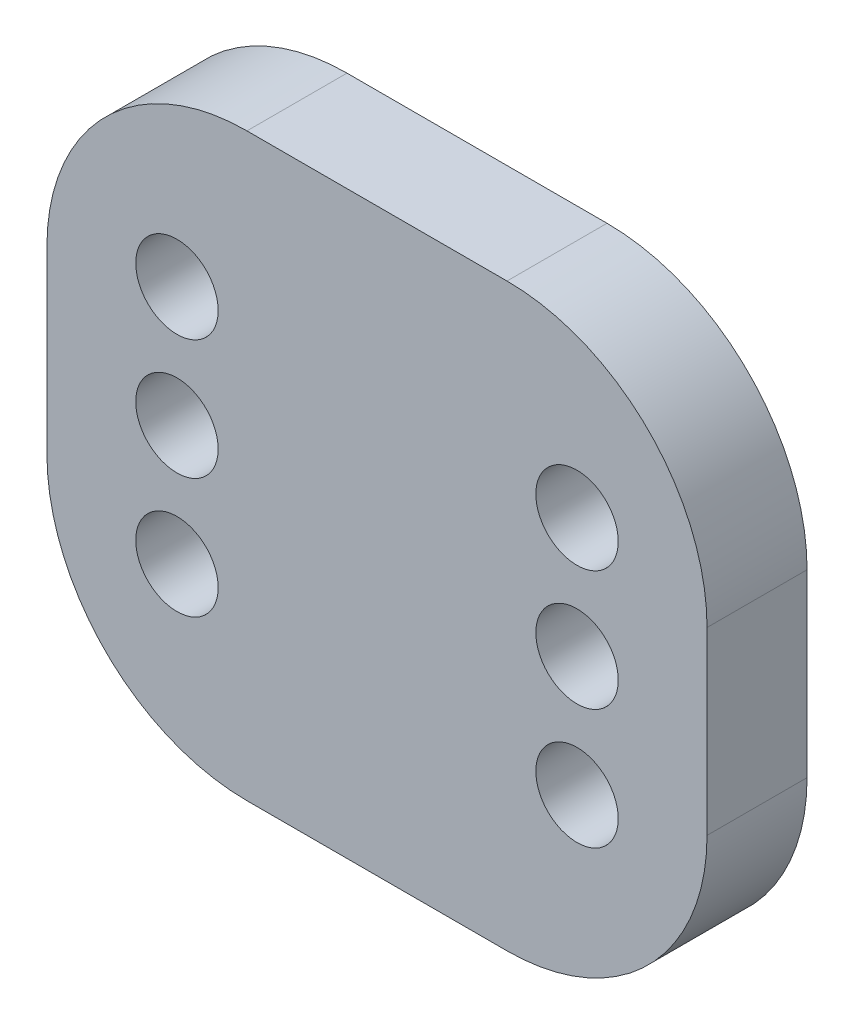
from build123d import *

# Parameters (mm, degrees)
SKETCH2_W           = 41.91
SKETCH2_H           = 36.83
SKETCH2_R           = 2.6162
BOSS_EXTRUDE1_DEPTH = 6.35
FILLET1_R           = 12.7


with BuildPart() as part:
    # Sketch2 → Boss-Extrude1 (new body)
    with BuildSketch(Plane.XY):
        Rectangle(SKETCH2_W, SKETCH2_H)
        with Locations((-12.7, 0)):
            Circle(SKETCH2_R, mode=Mode.SUBTRACT)
        with Locations((12.7, 0)):
            Circle(SKETCH2_R, mode=Mode.SUBTRACT)
        with Locations((-12.7, 7.62)):
            Circle(SKETCH2_R, mode=Mode.SUBTRACT)
        with Locations((12.7, 7.62)):
            Circle(SKETCH2_R, mode=Mode.SUBTRACT)
        with Locations((-12.7, -7.62)):
            Circle(SKETCH2_R, mode=Mode.SUBTRACT)
        with Locations((12.7, -7.62)):
            Circle(SKETCH2_R, mode=Mode.SUBTRACT)
    extrude(amount=BOSS_EXTRUDE1_DEPTH)

    # Fillet1
    fillet1_edges = [part.edges().sort_by_distance(p)[0] for p in [
        (20.955, -18.415, 3.175),
        (-20.955, -18.415, 3.175),
        (-20.955, 18.415, 3.175),
        (20.955, 18.415, 3.175),
    ]]
    fillet(fillet1_edges, radius=FILLET1_R)


solid = part.part
